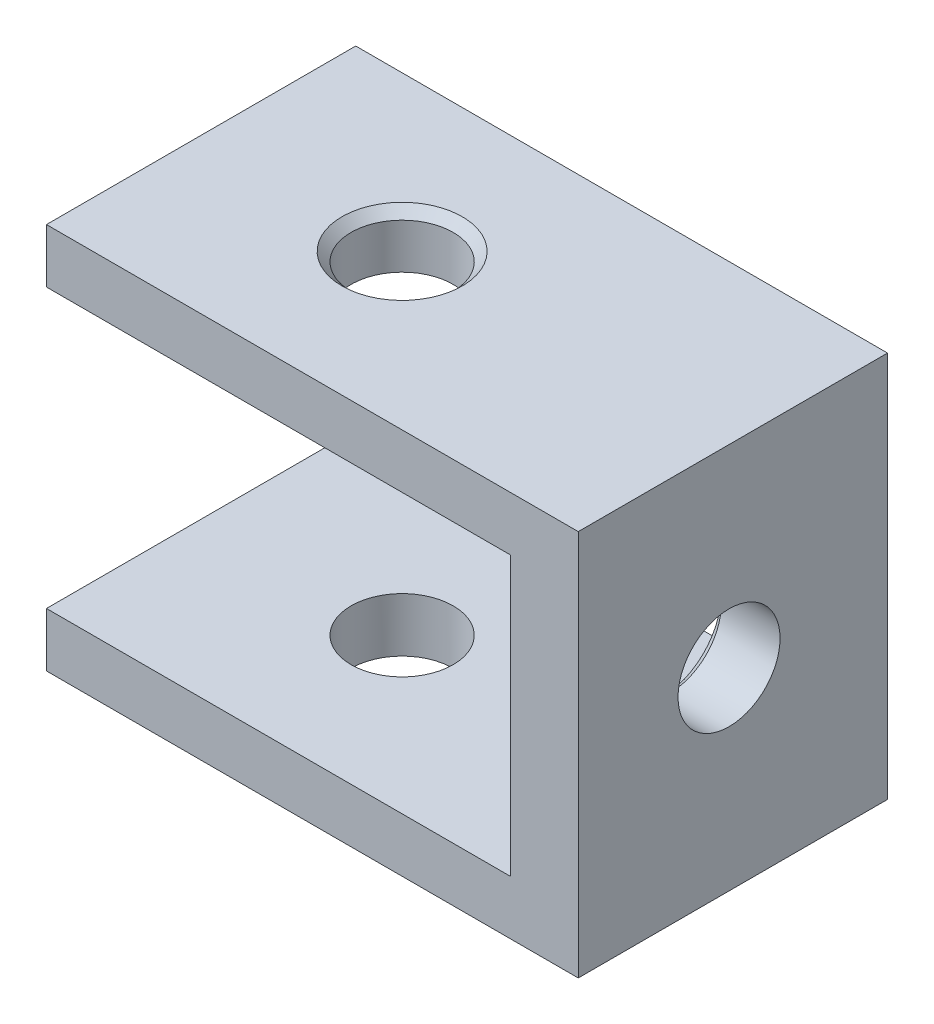
from build123d import *

# Parameters (mm, degrees)
SKETCH_1_W                      = 120
SKETCH_1_H                      = 20
EXTRUDE_1_DEPTH                 = 25
CUT_EXTRUDE_1_DEPTH             = 30
SKETCH_3_W                      = 15
SKETCH_3_H                      = 25
SKETCH_3_W_2                    = 70.609699787
CUT_EXTRUDE_2_DEPTH             = 30
HOLE_WIZARD_G1_16_1_D           = 6.6
HOLE_WIZARD_G1_16_1_DEPTH       = 30
HOLE_WIZARD_G1_16_1_CSINK_D     = 7.773
HOLE_WIZARD_G1_16_1_CSINK_ANGLE = 90
HOLE_WIZARD_G1_16_1_TIP         = 1.982840043
HOLE_WIZARD_G1_16_2_D           = 6.6
HOLE_WIZARD_G1_16_2_DEPTH       = 30
HOLE_WIZARD_G1_16_2_CSINK_D     = 7.773
HOLE_WIZARD_G1_16_2_CSINK_ANGLE = 90
HOLE_WIZARD_G1_16_2_TIP         = 1.982840043


with BuildPart() as part:
    # 草图1 → 凸台-拉伸1 (new body)
    with BuildSketch(Plane(origin=(0, 0, 0), x_dir=(1, 0, 0), z_dir=(0, 1, 0))):
        with Locations((10.609699787, 0.249516379)):
            Rectangle(SKETCH_1_W, SKETCH_1_H)
    extrude(amount=EXTRUDE_1_DEPTH)

    # 草图2 → 切除-拉伸1 (cut)
    with BuildSketch(Plane.ZY.offset(49.390300213)):
        Polygon((-10.249516379, 12.5), (-10.249516379, 21.5), (9.750483621, 21.5), (9.750483621, 3.5), (-10.249516379, 3.5), align=None)
    extrude(amount=-CUT_EXTRUDE_1_DEPTH, mode=Mode.SUBTRACT)

    # 草图3 → 切除-拉伸2 (cut)
    with BuildSketch(Plane.XY.offset(9.750483621)):
        with Locations((-7.5, 12.5)):
            Rectangle(SKETCH_3_W, SKETCH_3_H)
        with Locations((35.304849894, 12.5)):
            Rectangle(SKETCH_3_W_2, SKETCH_3_H)
    extrude(amount=-CUT_EXTRUDE_2_DEPTH, mode=Mode.SUBTRACT)

    # G1/16 螺纹孔1
    with Locations(Plane(origin=(0, 25, 0), x_dir=(1, 0, 0), z_dir=(0, 1, 0))):
        with Locations((-36.390300213, 0.249516379)):
            CounterSinkHole(HOLE_WIZARD_G1_16_1_D / 2, HOLE_WIZARD_G1_16_1_CSINK_D / 2, depth=HOLE_WIZARD_G1_16_1_DEPTH, counter_sink_angle=HOLE_WIZARD_G1_16_1_CSINK_ANGLE)
            with Locations((0, 0, -(HOLE_WIZARD_G1_16_1_DEPTH + HOLE_WIZARD_G1_16_1_TIP / 2))):  # 118° drill point
                Cone(0, HOLE_WIZARD_G1_16_1_D / 2, HOLE_WIZARD_G1_16_1_TIP, mode=Mode.SUBTRACT)

    # G1/16 螺纹孔2
    with Locations(Plane.ZY.offset(19.390300213)):
        with Locations((0, 12.5)):
            CounterSinkHole(HOLE_WIZARD_G1_16_2_D / 2, HOLE_WIZARD_G1_16_2_CSINK_D / 2, depth=HOLE_WIZARD_G1_16_2_DEPTH, counter_sink_angle=HOLE_WIZARD_G1_16_2_CSINK_ANGLE)
            with Locations((0, 0, -(HOLE_WIZARD_G1_16_2_DEPTH + HOLE_WIZARD_G1_16_2_TIP / 2))):  # 118° drill point
                Cone(0, HOLE_WIZARD_G1_16_2_D / 2, HOLE_WIZARD_G1_16_2_TIP, mode=Mode.SUBTRACT)


solid = part.part
